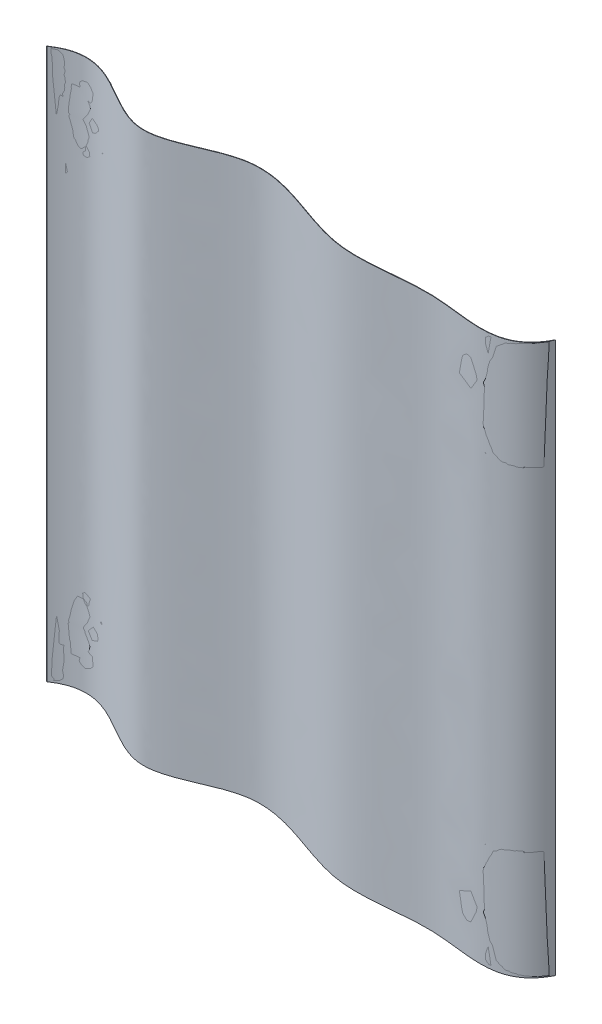
from build123d import *

# Parameters (mm, degrees)
BOSS_EXTRUDE1_DEPTH = 680


with BuildPart() as part:
    # Sketch2 → Boss-Extrude1 (new body)
    with BuildSketch(Plane(origin=(0, 0, 0), x_dir=(1, 0, 0), z_dir=(0, 1, 0))):
        with BuildLine():
            add(Edge.make_bspline(
                [(510.304726599, -28.488777413), (540.881929629, -30.066347158), (572.933760467, -38.725534487), (598.072579051, -29.226322392)],
                knots=[0.801238187, 0.801238187, 0.801238187, 0.801238187, 0.935347959, 0.935347959, 0.935347959, 0.935347959], degree=3))
            Line((510.304726599, -28.488777413), (510.304726599, -28.988777413))
            add(Edge.make_bspline(
                [(510.304726599, -28.988777413), (540.871243579, -30.53513697), (572.898739554, -39.123323621), (598.072579051, -29.726322392)],
                knots=[0.800220717, 0.800220717, 0.800220717, 0.800220717, 0.934288428, 0.934288428, 0.934288428, 0.934288428], degree=3))
            Line((598.072579051, -29.726322392), (598.072579051, -29.226322392))
        make_face()
        with BuildLine():
            add(Edge.make_bspline(
                [(598.072579051, -29.226322392), (610.191576051, -24.646913757), (620.703961242, -15.847420174), (628.67, 0)],
                knots=[0.935347959, 0.935347959, 0.935347959, 0.935347959, 1, 1, 1, 1], degree=3))
            Line((598.072579051, -29.226322392), (598.072579051, -29.726322392))
            add(Edge.make_bspline(
                [(598.072579051, -29.726322392), (610.411214003, -25.120502615), (621.103364457, -16.19402085), (629.17, 0)],
                knots=[0.934288428, 0.934288428, 0.934288428, 0.934288428, 1, 1, 1, 1], degree=3))
            Line((629.17, 0), (628.67, 0))
        make_face()
        with BuildLine():
            add(Edge.make_bspline(
                [(392.297530026, -31.438957328), (430.724811221, -37.054514475), (469.181127264, -26.367087406), (510.304726599, -28.488777413)],
                knots=[0.620872555, 0.620872555, 0.620872555, 0.620872555, 0.801238187, 0.801238187, 0.801238187, 0.801238187], degree=3))
            Line((392.297530026, -31.438957328), (392.297530026, -31.938957328))
            add(Edge.make_bspline(
                [(392.297530026, -31.938957328), (430.728867022, -37.566491887), (469.195499044, -26.909062314), (510.304726599, -28.988777413)],
                knots=[0.619911653, 0.619911653, 0.619911653, 0.619911653, 0.800220717, 0.800220717, 0.800220717, 0.800220717], degree=3))
            Line((510.304726599, -28.988777413), (510.304726599, -28.488777413))
        make_face()
        with BuildLine():
            add(Edge.make_bspline(
                [(247.001169245, 0.5), (295.48747786, 8.608083076), (343.869446836, -24.361936517), (392.297530026, -31.438957328)],
                knots=[0.393566289, 0.393566289, 0.393566289, 0.393566289, 0.620872555, 0.620872555, 0.620872555, 0.620872555], degree=3))
            Line((247.001169245, 0.5), (247.001169245, 0))
            add(Edge.make_bspline(
                [(247.001169245, 0), (295.487197833, 8.109652046), (343.864335501, -24.846841952), (392.297530026, -31.938957328)],
                knots=[0.392676675, 0.392676675, 0.392676675, 0.392676675, 0.619911653, 0.619911653, 0.619911653, 0.619911653], degree=3))
            Line((392.297530026, -31.938957328), (392.297530026, -31.438957328))
        make_face()
        with BuildLine():
            add(Edge.make_bspline(
                [(144.482417222, -29.226322392), (177.368057325, -32.283558402), (212.211471824, -5.317678535), (247.001169245, 0.5)],
                knots=[0.230470429, 0.230470429, 0.230470429, 0.230470429, 0.393566289, 0.393566289, 0.393566289, 0.393566289], degree=3))
            Line((144.482417222, -29.226322392), (144.482417222, -29.726322392))
            add(Edge.make_bspline(
                [(144.482417222, -29.726322392), (177.366116039, -32.779654306), (212.211672748, -5.818804296), (247.001169245, 0)],
                knots=[0.229631966, 0.229631966, 0.229631966, 0.229631966, 0.392676675, 0.392676675, 0.392676675, 0.392676675], degree=3))
            Line((247.001169245, 0), (247.001169245, 0.5))
        make_face()
        with BuildLine():
            add(Edge.make_bspline(
                [(78.10336915, 0.5), (100.576308596, -11.121079274), (122.074890093, -27.143191316), (144.482417222, -29.226322392)],
                knots=[0.119340619, 0.119340619, 0.119340619, 0.119340619, 0.230470429, 0.230470429, 0.230470429, 0.230470429], degree=3))
            Line((78.10336915, 0.5), (78.10336915, 0))
            add(Edge.make_bspline(
                [(78.10336915, 0), (100.580849955, -11.63054741), (122.07621284, -27.645851479), (144.482417222, -29.726322392)],
                knots=[0.11853701, 0.11853701, 0.11853701, 0.11853701, 0.229631966, 0.229631966, 0.229631966, 0.229631966], degree=3))
            Line((144.482417222, -29.726322392), (144.482417222, -29.226322392))
        make_face()
        with BuildLine():
            add(Edge.make_bspline(
                [(0, 0), (28.713013056, 20.384004821), (53.970019868, 12.979701012), (78.10336915, 0.5)],
                knots=[0, 0, 0, 0, 0.119340619, 0.119340619, 0.119340619, 0.119340619], degree=3))
            Line((0, 0), (0.5, 0))
            add(Edge.make_bspline(
                [(0.5, 0), (29.018848774, 19.827427202), (54.120161846, 12.409657114), (78.10336915, 0)],
                knots=[0, 0, 0, 0, 0.11853701, 0.11853701, 0.11853701, 0.11853701], degree=3))
            Line((78.10336915, 0), (78.10336915, 0.5))
        make_face()
    extrude(amount=BOSS_EXTRUDE1_DEPTH)


solid = part.part
